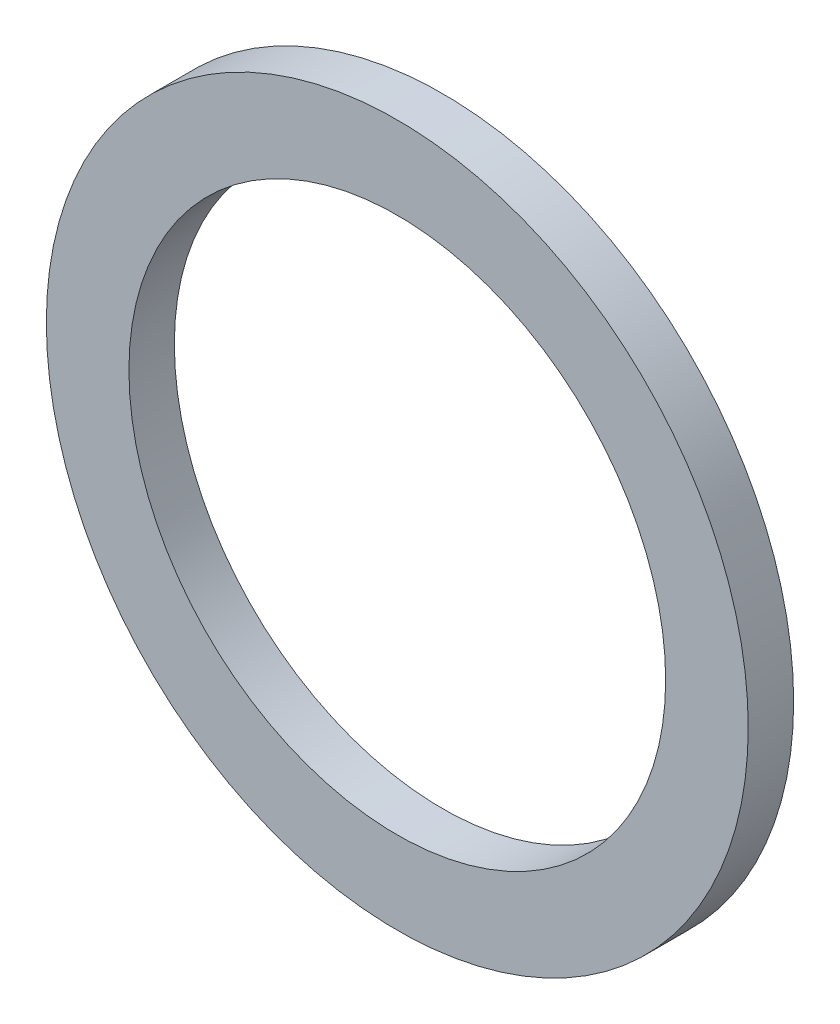
from build123d import *

# Parameters (mm, degrees)
SKETCH1_R      = 4.318
SKETCH1_R_2    = 3.302
EXTRUDE1_DEPTH = 0.5588


with BuildPart() as part:
    # Sketch1 → Extrude1 (new body)
    with BuildSketch(Plane.XY):
        Circle(SKETCH1_R)
        Circle(SKETCH1_R_2, mode=Mode.SUBTRACT)
    extrude(amount=-EXTRUDE1_DEPTH)


solid = part.part
